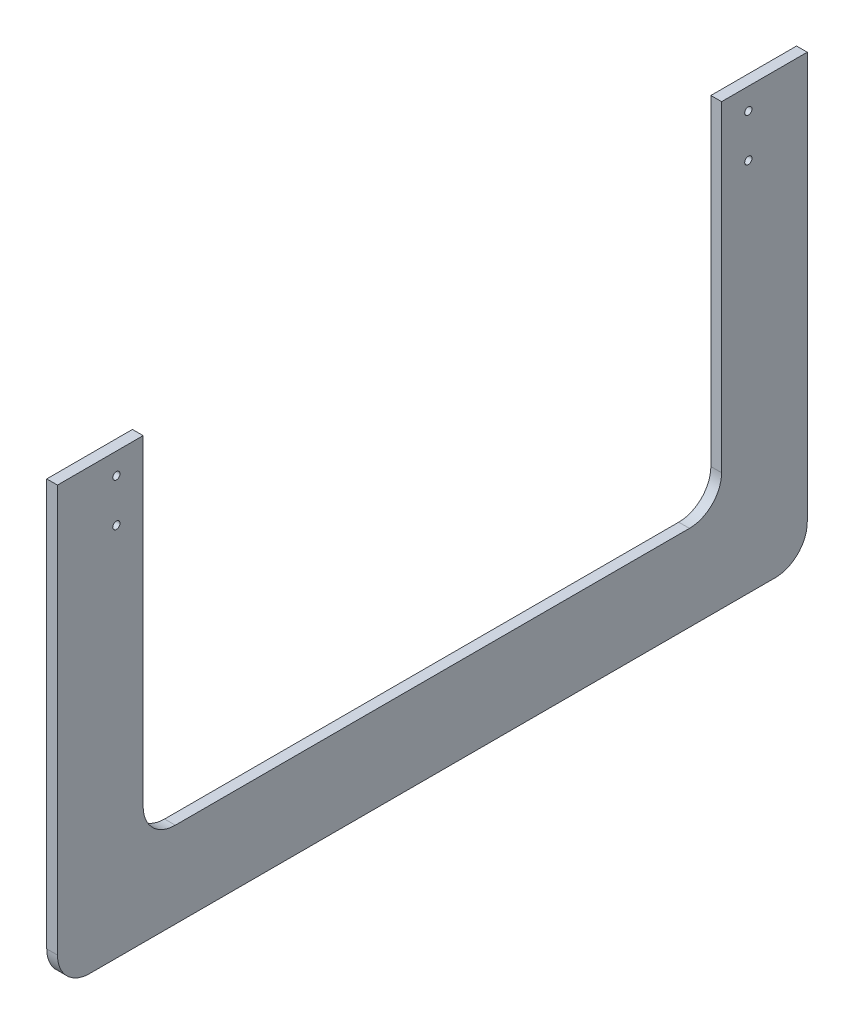
from build123d import *

# Parameters (mm, degrees)
BOSS_EXTRUDE2_DEPTH                               = 6.35
CSK_FOR_8_FLAT_HEAD_SOCKET_CAP_SCREW1_D           = 4.3053
CSK_FOR_8_FLAT_HEAD_SOCKET_CAP_SCREW1_CSINK_D     = 9.1186
CSK_FOR_8_FLAT_HEAD_SOCKET_CAP_SCREW1_CSINK_ANGLE = 82


with BuildPart() as part:
    # Sketch1 → Boss-Extrude2 (new body)
    with BuildSketch(Plane(origin=(0, 0, 0), x_dir=(0, 0, -1), z_dir=(1, 0, 0))):
        with BuildLine():
            Line((-222.25, 0), (-171.45, 0))
            Line((-171.45, 0), (-171.45, -190.5))
            ThreePointArc((-171.45, -190.5), (-165.870384182, -203.970384182), (-152.4, -209.55))
            Line((-152.4, -209.55), (152.4, -209.55))
            ThreePointArc((152.4, -209.55), (165.870384182, -203.970384182), (171.45, -190.5))
            Line((171.45, -190.5), (171.45, 0))
            Line((171.45, 0), (222.25, 0))
            Line((222.25, 0), (222.25, -241.3))
            ThreePointArc((222.25, -241.3), (216.670384182, -254.770384182), (203.2, -260.35))
            Line((203.2, -260.35), (-203.2, -260.35))
            ThreePointArc((-203.2, -260.35), (-216.670384182, -254.770384182), (-222.25, -241.3))
            Line((-222.25, -241.3), (-222.25, 0))
        make_face()
    extrude(amount=BOSS_EXTRUDE2_DEPTH)

    # CSK for #8 Flat Head Socket Cap Screw1 (through all)
    with Locations(Plane.ZY):
        with Locations((-187.325, -12.7), (-187.325, -38.1)):
            csk_for_8_flat_head_socket_cap_screw1 = CounterSinkHole(CSK_FOR_8_FLAT_HEAD_SOCKET_CAP_SCREW1_D / 2, CSK_FOR_8_FLAT_HEAD_SOCKET_CAP_SCREW1_CSINK_D / 2, counter_sink_angle=CSK_FOR_8_FLAT_HEAD_SOCKET_CAP_SCREW1_CSINK_ANGLE)

    # Mirror1: CSK for #8 Flat Head Socket Cap Screw1 across plane
    add(csk_for_8_flat_head_socket_cap_screw1.mirror(Plane.XY), mode=Mode.SUBTRACT)


solid = part.part
